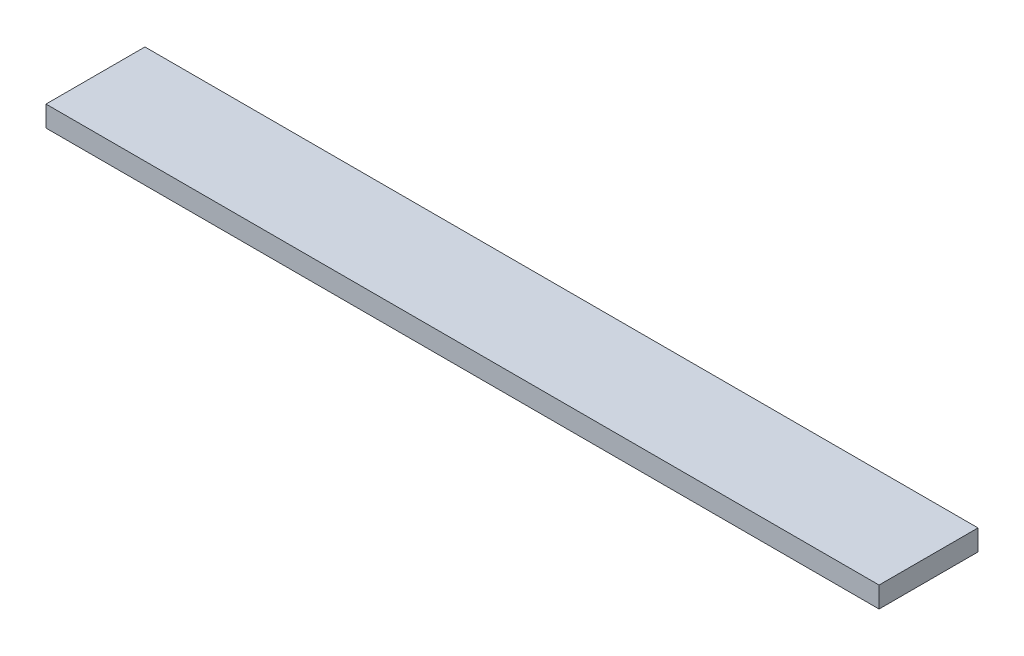
from build123d import *

# Parameters (mm, degrees)
SKETCH1_W           = 101.6
SKETCH1_H           = 12.065
BOSS_EXTRUDE1_DEPTH = 2.54


with BuildPart() as part:
    # Sketch1 → Boss-Extrude1 (new body)
    with BuildSketch(Plane(origin=(0, 0, 0), x_dir=(1, 0, 0), z_dir=(0, 1, 0))):
        with Locations((50.8, 6.0325)):
            Rectangle(SKETCH1_W, SKETCH1_H)
    extrude(amount=BOSS_EXTRUDE1_DEPTH)


solid = part.part
